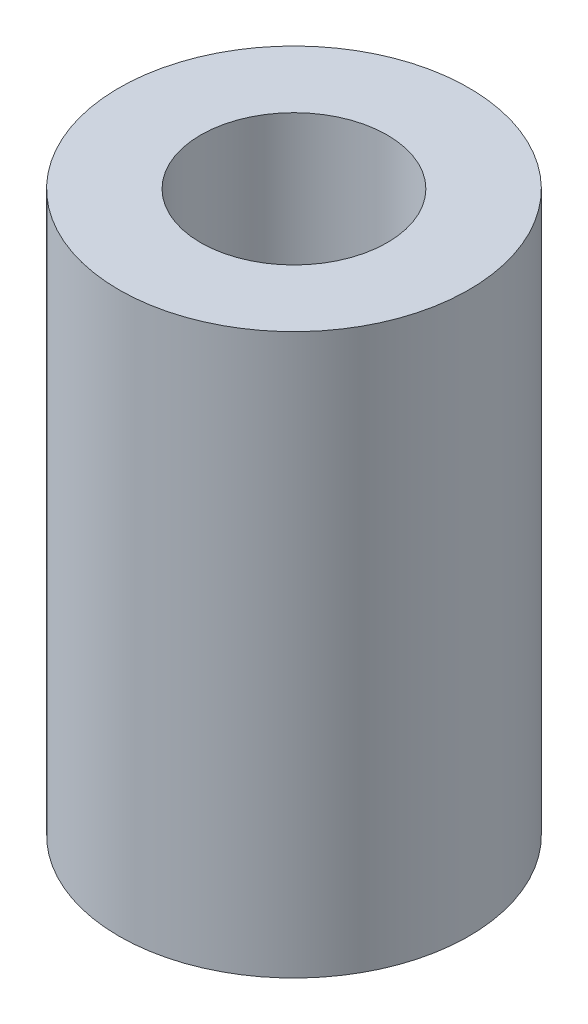
from build123d import *

# Parameters (mm, degrees)
SKETCH_1_R          = 7.5
EXTRUDE_1_DEPTH     = 24
SKETCH_2_R          = 4
CUT_EXTRUDE_1_DEPTH = 25


with BuildPart() as part:
    # 草图1 → 凸台-拉伸1 (new body)
    with BuildSketch(Plane(origin=(0, 0, 0), x_dir=(1, 0, 0), z_dir=(0, 1, 0))):
        Circle(SKETCH_1_R)
    extrude(amount=EXTRUDE_1_DEPTH)

    # 草图2 → 切除-拉伸1 (cut, through all)
    with BuildSketch(Plane(origin=(0, 24, 0), x_dir=(1, 0, 0), z_dir=(0, 1, 0))):
        Circle(SKETCH_2_R)
    extrude(amount=-CUT_EXTRUDE_1_DEPTH, mode=Mode.SUBTRACT)


solid = part.part
